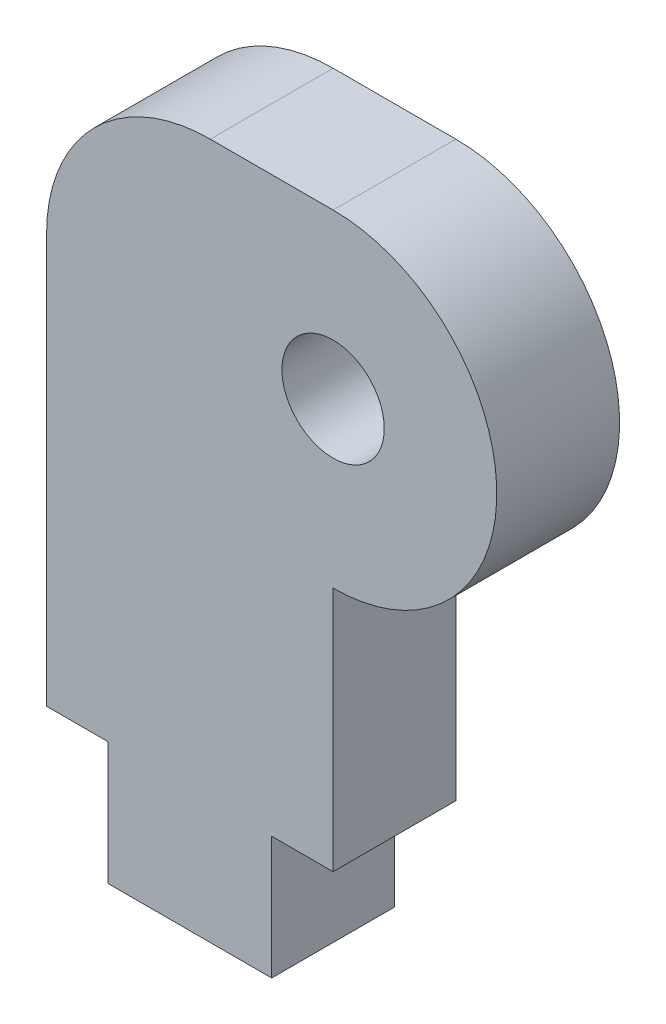
from build123d import *

# Parameters (mm, degrees)
SKETCH1_R           = 1.25
BOSS_EXTRUDE1_DEPTH = 3
FILLET1_R           = 4


with BuildPart() as part:
    # Sketch1 → Boss-Extrude1 (new body)
    with BuildSketch(Plane.XY):
        with BuildLine():
            Line((-7, 4), (-7, -10))
            Line((-7, -10), (-5.5, -10))
            Line((-5.5, -10), (-5.5, -13))
            Line((-5.5, -13), (-1.5, -13))
            Line((-1.5, -13), (-1.5, -10))
            Line((-1.5, -10), (0, -10))
            Line((0, -10), (0, -4))
            ThreePointArc((0, -4), (4, 0), (0, 4))
            Line((0, 4), (-7, 4))
        make_face()
        Circle(SKETCH1_R, mode=Mode.SUBTRACT)
    extrude(amount=BOSS_EXTRUDE1_DEPTH)

    # Fillet1
    fillet1_edges = [part.edges().sort_by_distance(p)[0] for p in [
        (-7, 4, 1.5),
    ]]
    fillet(fillet1_edges, radius=FILLET1_R)


solid = part.part
